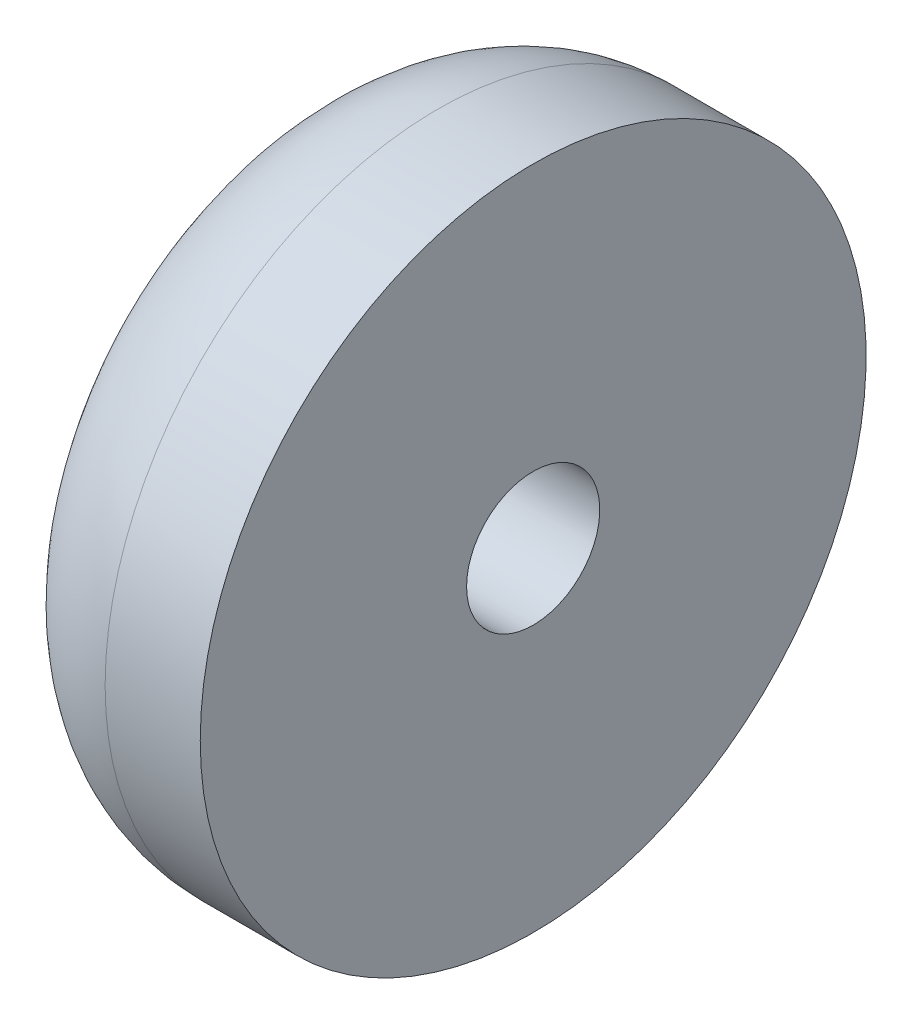
from build123d import *

# Parameters (mm, degrees)
CROQUIS6_R              = 7
CROQUIS6_R_2            = 1.4
SALIENTE_EXTRUIR4_DEPTH = 5
REDONDEO2_R             = 3
CROQUIS7_R              = 3
CORTAR_EXTRUIR2_DEPTH   = 3


with BuildPart() as part:
    # Croquis6 → Saliente-Extruir4 (new body)
    with BuildSketch(Plane.ZY.offset(29.169607513)):
        with Locations((65.25, 31.063666838)):
            Circle(CROQUIS6_R)
        with Locations((65.25, 31.063666838)):
            Circle(CROQUIS6_R_2, mode=Mode.SUBTRACT)
    extrude(amount=SALIENTE_EXTRUIR4_DEPTH)

    # Redondeo2
    redondeo2_edges = [part.edges().sort_by_distance(p)[0] for p in [
        (-34.169607513, 31.063666838, 58.25),
    ]]
    fillet(redondeo2_edges, radius=REDONDEO2_R)

    # Croquis7 → Cortar-Extruir2 (cut)
    with BuildSketch(Plane.ZY.offset(34.169607513)):
        with Locations((65.25, 31.063666838)):
            Circle(CROQUIS7_R)
    extrude(amount=-CORTAR_EXTRUIR2_DEPTH, mode=Mode.SUBTRACT)


solid = part.part
